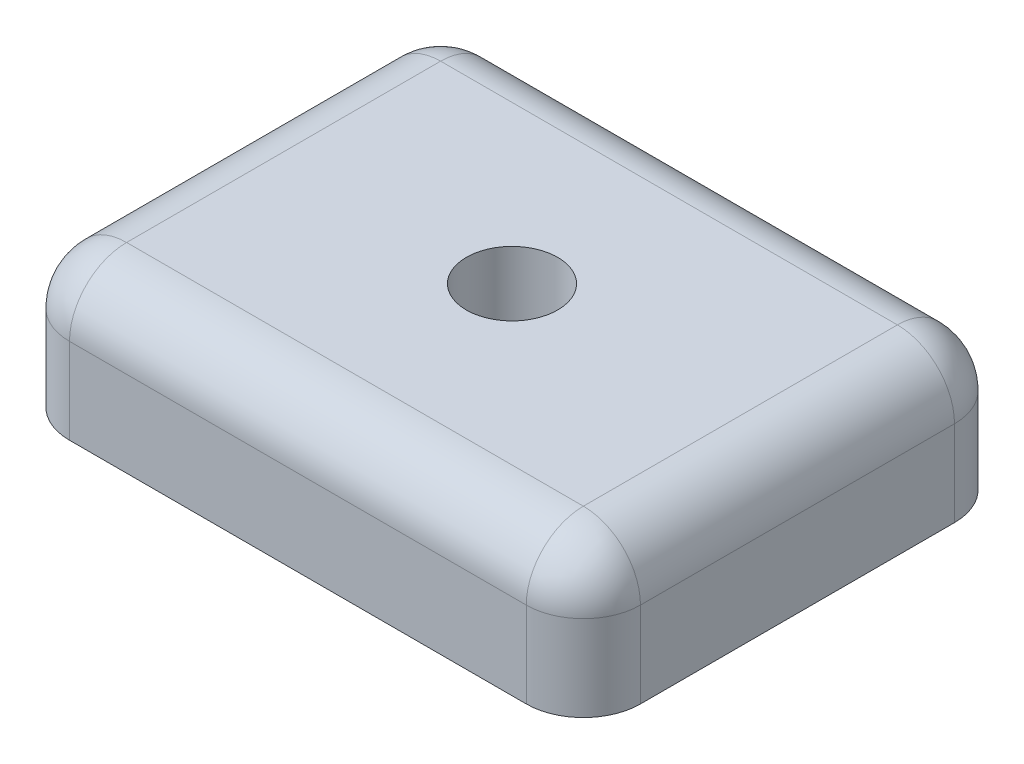
from build123d import *

# Parameters (mm, degrees)
SKETCH2_W           = 20
SKETCH2_H           = 15
BOSS_EXTRUDE1_DEPTH = 5
SKETCH3_R           = 1.6
CUT_EXTRUDE1_DEPTH  = 6
FILLET1_R           = 2


with BuildPart() as part:
    # Sketch2 → Boss-Extrude1 (new body)
    with BuildSketch(Plane(origin=(0, 0, 0), x_dir=(1, 0, 0), z_dir=(0, 1, 0))):
        with Locations((10, 7.5)):
            Rectangle(SKETCH2_W, SKETCH2_H)
    extrude(amount=BOSS_EXTRUDE1_DEPTH)

    # Sketch3 → Cut-Extrude1 (cut, through all)
    with BuildSketch(Plane(origin=(0, 5, 0), x_dir=(1, 0, 0), z_dir=(0, 1, 0))):
        with Locations((10, 7.5)):
            Circle(SKETCH3_R)
    extrude(amount=-CUT_EXTRUDE1_DEPTH, mode=Mode.SUBTRACT)

    # Fillet1
    fillet1_edges = [part.edges().sort_by_distance(p)[0] for p in [
        (10, 5, -15),
        (0, 5, -7.5),
        (10, 5, 0),
        (0, 2.5, 0),
        (0, 2.5, -15),
        (20, 2.5, -15),
        (20, 2.5, 0),
        (20, 5, -7.5),
    ]]
    fillet(fillet1_edges, radius=FILLET1_R)


solid = part.part
